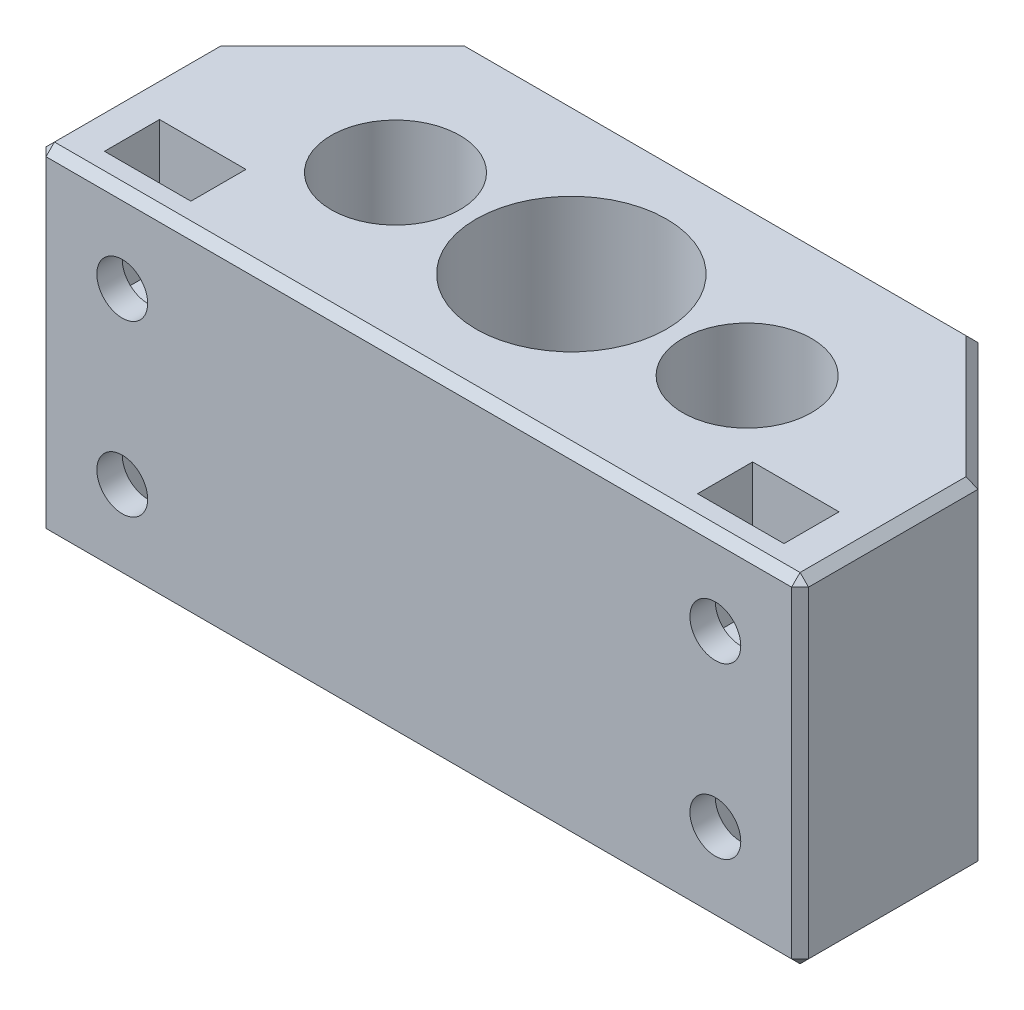
from build123d import *

# Parameters (mm, degrees)
SKETCH1_W           = 90
SKETCH1_H           = 36
SKETCH1_R           = 5.25
SKETCH1_R_2         = 7.6
BOSS_EXTRUDE1_DEPTH = 20
SKETCH2_R           = 11.25
CUT_EXTRUDE1_DEPTH  = 20
CHAMFER1_SIZE       = 15
CUT_EXTRUDE2_REACH  = 22
SKETCH4_R           = 1.65
SKETCH11_R          = 2.65
CUT_EXTRUDE7_DEPTH  = 5.3
SKETCH12_R          = 3
CUT_EXTRUDE8_DEPTH  = 5
CUT_EXTRUDE10_START = -3
SKETCH14_W          = 10.2
SKETCH14_H          = 10.5
SKETCH14_R          = 3
SKETCH14_H_2        = 4.75
CUT_EXTRUDE10_DEPTH = 6.5
CHAMFER2_SIZE       = 1


with BuildPart() as part:
    # Sketch1 → Boss-Extrude1 (new body, symmetric)
    with BuildSketch(Plane(origin=(0, 0, 0), x_dir=(1, 0, 0), z_dir=(0, 1, 0))):
        Rectangle(SKETCH1_W, SKETCH1_H)
        Circle(SKETCH1_R, mode=Mode.SUBTRACT)
        with Locations((-20.75, 0)):
            Circle(SKETCH1_R_2, mode=Mode.SUBTRACT)
        with Locations((20.75, 0)):
            Circle(SKETCH1_R_2, mode=Mode.SUBTRACT)
    extrude(amount=BOSS_EXTRUDE1_DEPTH, both=True)

    # Sketch2 → Cut-Extrude1 (cut)
    with BuildSketch(Plane(origin=(0, 20, 0), x_dir=(1, 0, 0), z_dir=(0, 1, 0))):
        Circle(SKETCH2_R)
    extrude(amount=-CUT_EXTRUDE1_DEPTH, mode=Mode.SUBTRACT)

    # Chamfer1
    chamfer1_edges = [part.edges().sort_by_distance(p)[0] for p in [
        (-45, 0, -18),
        (45, 0, -18),
    ]]
    chamfer(chamfer1_edges, length=CHAMFER1_SIZE)

    # Sketch4 → Cut-Extrude2 (cut, up to next)
    with BuildSketch(Plane(origin=(0, 0, 0), x_dir=(1, 0, 0), z_dir=(0, 1, 0)), mode=Mode.PRIVATE) as cut_extrude2_sk1:
        with Locations((0, 8)):
            Circle(SKETCH4_R)
    cut_extrude2_tool1 = extrude(cut_extrude2_sk1.sketch, amount=-CUT_EXTRUDE2_REACH, mode=Mode.PRIVATE) & part.part
    add(cut_extrude2_tool1.solids().sort_by_distance((0, 0, -8))[0], mode=Mode.SUBTRACT)
    # Sketch4 → Cut-Extrude2 (cut, up to next)
    with BuildSketch(Plane(origin=(0, 0, 0), x_dir=(1, 0, 0), z_dir=(0, 1, 0)), mode=Mode.PRIVATE) as cut_extrude2_sk2:
        with Locations((8, 0)):
            Circle(SKETCH4_R)
    cut_extrude2_tool2 = extrude(cut_extrude2_sk2.sketch, amount=-CUT_EXTRUDE2_REACH, mode=Mode.PRIVATE) & part.part
    add(cut_extrude2_tool2.solids().sort_by_distance((8, 0, 0))[0], mode=Mode.SUBTRACT)
    # Sketch4 → Cut-Extrude2 (cut, up to next)
    with BuildSketch(Plane(origin=(0, 0, 0), x_dir=(1, 0, 0), z_dir=(0, 1, 0)), mode=Mode.PRIVATE) as cut_extrude2_sk3:
        with Locations((0, -8)):
            Circle(SKETCH4_R)
    cut_extrude2_tool3 = extrude(cut_extrude2_sk3.sketch, amount=-CUT_EXTRUDE2_REACH, mode=Mode.PRIVATE) & part.part
    add(cut_extrude2_tool3.solids().sort_by_distance((0, 0, 8))[0], mode=Mode.SUBTRACT)
    # Sketch4 → Cut-Extrude2 (cut, up to next)
    with BuildSketch(Plane(origin=(0, 0, 0), x_dir=(1, 0, 0), z_dir=(0, 1, 0)), mode=Mode.PRIVATE) as cut_extrude2_sk4:
        with Locations((-8, 0)):
            Circle(SKETCH4_R)
    cut_extrude2_tool4 = extrude(cut_extrude2_sk4.sketch, amount=-CUT_EXTRUDE2_REACH, mode=Mode.PRIVATE) & part.part
    add(cut_extrude2_tool4.solids().sort_by_distance((-8, 0, 0))[0], mode=Mode.SUBTRACT)

    # Sketch11 → Cut-Extrude7 (cut)
    with BuildSketch(Plane.XZ.offset(20)):
        with Locations((-8, 0)):
            Circle(SKETCH11_R)
        with Locations((0, 8)):
            Circle(SKETCH11_R)
        with Locations((8, 0)):
            Circle(SKETCH11_R)
        with Locations((0, -8)):
            Circle(SKETCH11_R)
    extrude(amount=-CUT_EXTRUDE7_DEPTH, mode=Mode.SUBTRACT)

    # Sketch12 → Cut-Extrude8 (cut)
    with BuildSketch(Plane.XY.offset(18)):
        with Locations((-35, 10)):
            Circle(SKETCH12_R)
        with Locations((-35, -10)):
            Circle(SKETCH12_R)
        with Locations((35, -10)):
            Circle(SKETCH12_R)
        with Locations((35, 10)):
            Circle(SKETCH12_R)
    extrude(amount=-CUT_EXTRUDE8_DEPTH, mode=Mode.SUBTRACT)

    # Sketch14 → Cut-Extrude10 (cut)
    with BuildSketch(Plane.XY.offset(18).offset(CUT_EXTRUDE10_START)):
        with Locations((-35, 10)):
            Rectangle(SKETCH14_W, SKETCH14_H)
        with Locations((-35, 10)):
            Circle(SKETCH14_R, mode=Mode.SUBTRACT)
        with Locations((-35, 17.625)):
            Rectangle(SKETCH14_W, SKETCH14_H_2)
        with Locations((-35, -17.625)):
            Rectangle(SKETCH14_W, SKETCH14_H_2)
        with Locations((-35, -10)):
            Rectangle(SKETCH14_W, SKETCH14_H)
        with Locations((-35, -10)):
            Circle(SKETCH14_R, mode=Mode.SUBTRACT)
        with Locations((35, -10)):
            Rectangle(SKETCH14_W, SKETCH14_H)
        with Locations((35, -10)):
            Circle(SKETCH14_R, mode=Mode.SUBTRACT)
        with Locations((35, -17.625)):
            Rectangle(SKETCH14_W, SKETCH14_H_2)
        with Locations((35, 10)):
            Rectangle(SKETCH14_W, SKETCH14_H)
        with Locations((35, 10)):
            Circle(SKETCH14_R, mode=Mode.SUBTRACT)
        with Locations((35, 17.625)):
            Rectangle(SKETCH14_W, SKETCH14_H_2)
        with Locations((-35, -10)):
            Circle(SKETCH14_R)
        with Locations((35, -10)):
            Circle(SKETCH14_R)
        with Locations((35, 10)):
            Circle(SKETCH14_R)
        with Locations((-35, 10)):
            Circle(SKETCH14_R)
    extrude(amount=-CUT_EXTRUDE10_DEPTH, mode=Mode.SUBTRACT)

    # Chamfer2
    chamfer2_edges = [part.edges().sort_by_distance(p)[0] for p in [
        (0, -20, 18),
        (0, 20, -18),
        (-45, 20, 7.5),
        (-37.5, 20, -10.5),
        (37.5, 20, -10.5),
        (0, -20, -18),
        (-45, -20, 7.5),
        (-37.5, -20, -10.5),
        (37.5, -20, -10.5),
        (45, -20, 7.5),
        (0, 20, 18),
        (45, 20, 7.5),
        (45, 0, 18),
        (-45, 0, 18),
    ]]
    chamfer(chamfer2_edges, length=CHAMFER2_SIZE)


solid = part.part
